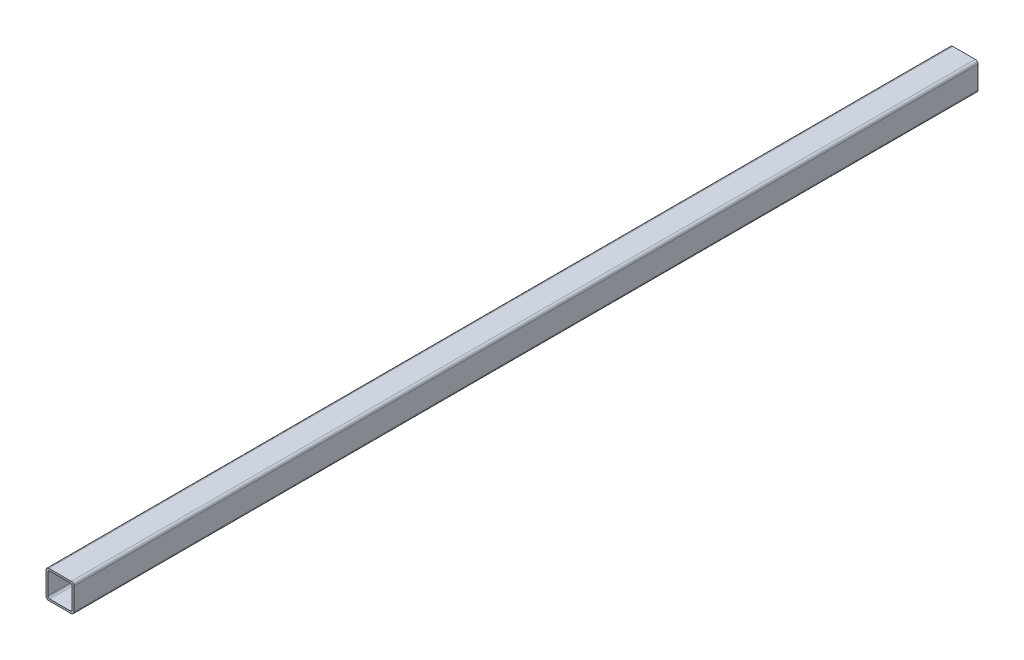
from build123d import *

# Parameters (mm, degrees)
EXTRUDE_1_DEPTH = 484.6


with BuildPart() as part:
    # Эскиз1 → Бобышка-Вытянуть1 (new body)
    with BuildSketch(Plane.XY):
        with BuildLine():
            Line((-12, 15), (12, 15))
            ThreePointArc((12, 15), (14.121320344, 14.121320344), (15, 12))
            Line((15, 12), (15, -12))
            ThreePointArc((15, -12), (14.121320344, -14.121320344), (12, -15))
            Line((12, -15), (-12, -15))
            ThreePointArc((-12, -15), (-14.121320344, -14.121320344), (-15, -12))
            Line((-15, -12), (-15, 12))
            ThreePointArc((-15, 12), (-14.121320344, 14.121320344), (-12, 15))
        make_face()
        with BuildLine():
            Line((-11, 13), (11, 13))
            ThreePointArc((11, 13), (12.414213562, 12.414213562), (13, 11))
            Line((13, 11), (13, -11))
            ThreePointArc((13, -11), (12.414213562, -12.414213562), (11, -13))
            Line((11, -13), (-11, -13))
            ThreePointArc((-11, -13), (-12.414213562, -12.414213562), (-13, -11))
            Line((-13, -11), (-13, 11))
            ThreePointArc((-13, 11), (-12.414213562, 12.414213562), (-11, 13))
        make_face(mode=Mode.SUBTRACT)
    extrude(amount=EXTRUDE_1_DEPTH)

    # Зеркальное отражение1: part across plane


with BuildPart() as part_1:
    add(part.part)
    add(part.part.mirror(Plane(origin=(-12, -12, 0), x_dir=(1, 0, 0), z_dir=(0, 0, 1))))


solid = part_1.part
